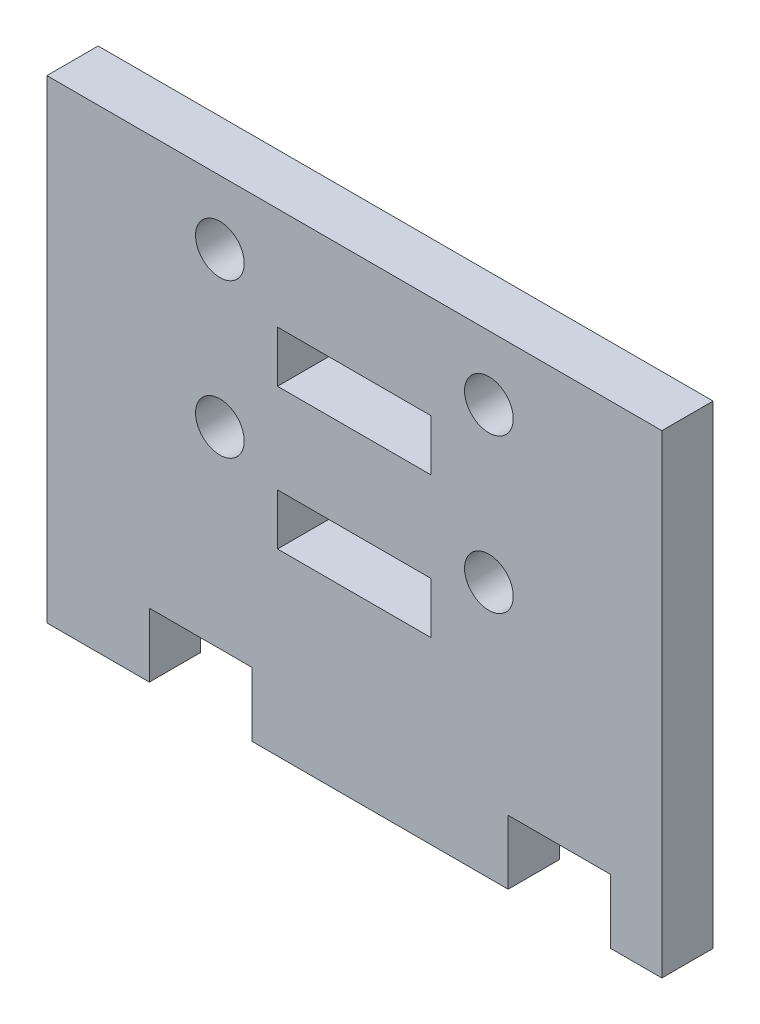
from build123d import *

# Parameters (mm, degrees)
SKETCH1_R           = 0.95
SKETCH1_W           = 6
SKETCH1_H           = 2
BOSS_EXTRUDE1_DEPTH = 2


with BuildPart() as part:
    # Sketch1 → Boss-Extrude1 (new body)
    with BuildSketch(Plane.XY):
        Polygon((4, 2.5), (8, 2.5), (8, 0), (18, 0), (18, 2.5), (22, 2.5), (22, 0), (24, 0), (24, 18.5), (0, 18.5), (0, 0), (4, 0), align=None)
        with Locations((6.75, 16)):
            Circle(SKETCH1_R, mode=Mode.SUBTRACT)
        with Locations((17.25, 10)):
            Circle(SKETCH1_R, mode=Mode.SUBTRACT)
        with Locations((17.25, 16)):
            Circle(SKETCH1_R, mode=Mode.SUBTRACT)
        with Locations((6.75, 10)):
            Circle(SKETCH1_R, mode=Mode.SUBTRACT)
        with Locations((12, 13.5)):
            Rectangle(SKETCH1_W, SKETCH1_H, mode=Mode.SUBTRACT)
        with Locations((12, 8)):
            Rectangle(SKETCH1_W, SKETCH1_H, mode=Mode.SUBTRACT)
    extrude(amount=BOSS_EXTRUDE1_DEPTH)


solid = part.part
